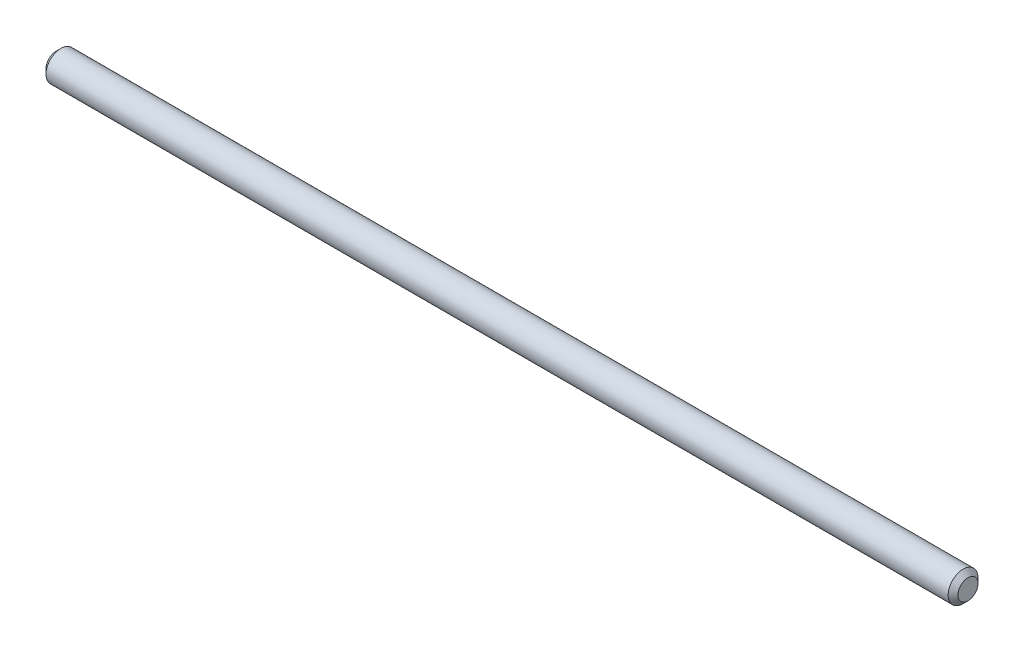
from build123d import *

# Parameters (mm, degrees)
SKETCH2_R                = 2.413
BOSS_EXTRUDE1_DEPTH      = 73.66
BOSS_EXTRUDE1_DEPTH_BACK = 73.66
CHAMFER1_SIZE            = 0.79375


with BuildPart() as part:
    # Sketch2 → Boss-Extrude1 (new body, two sides)
    with BuildSketch(Plane(origin=(0, 0, 0), x_dir=(0, 0, -1), z_dir=(1, 0, 0))) as boss_extrude1_sk:
        Circle(SKETCH2_R)
    extrude(amount=BOSS_EXTRUDE1_DEPTH)
    extrude(boss_extrude1_sk.sketch, amount=-BOSS_EXTRUDE1_DEPTH_BACK)

    # Chamfer1
    chamfer1_edges = [part.edges().sort_by_distance(p)[0] for p in [
        (-73.66, 0, 2.413),
        (73.66, 0, 2.413),
    ]]
    chamfer(chamfer1_edges, length=CHAMFER1_SIZE)


solid = part.part
